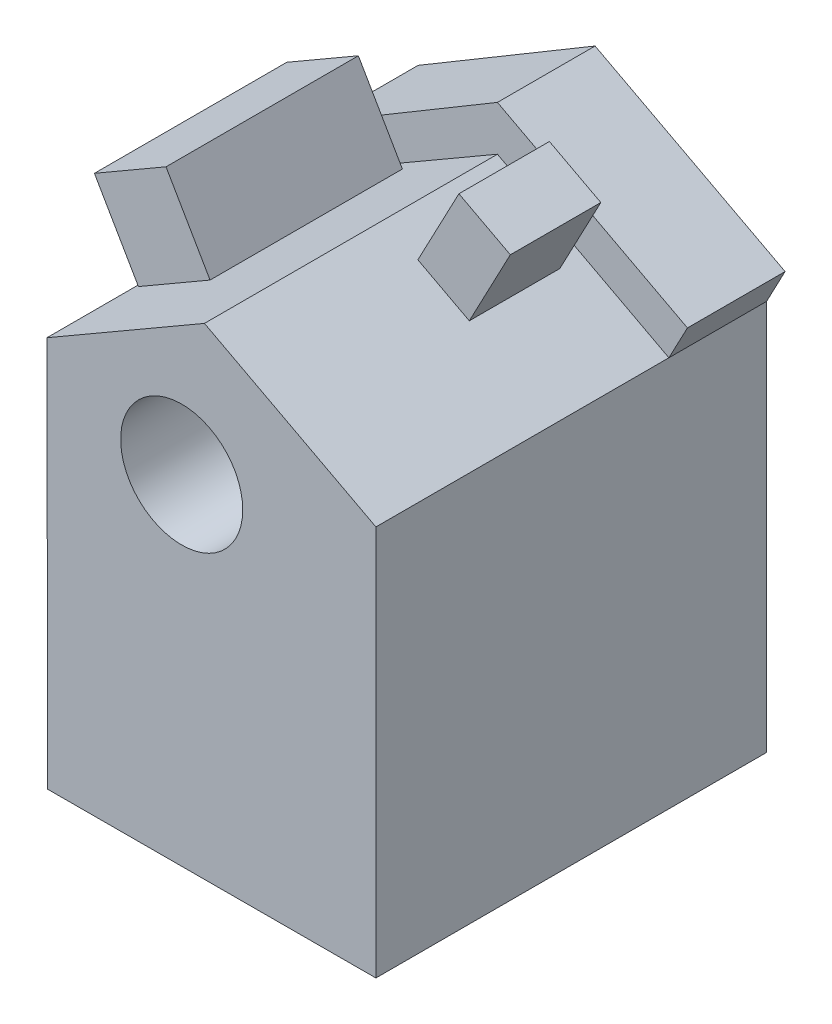
from build123d import *

# Parameters (mm, degrees)
BOSS_EXTRUDE1_DEPTH = 40
SKETCH5_R           = 6.25
CUT_EXTRUDE6_DEPTH  = 10
BOSS_EXTRUDE2_DEPTH = 10
SKETCH8_W           = 5.952717485
SKETCH8_H           = 9.266101102
BOSS_EXTRUDE3_DEPTH = 9
SKETCH9_W           = 8.470991549
SKETCH9_H           = 19.695284028
BOSS_EXTRUDE4_DEPTH = 9


with BuildPart() as part:
    # Sketch4 → Boss-Extrude1 (new body)
    with BuildSketch(Plane.XY):
        Polygon((0, 0), (33.61, 0.067089629), (33.61, 40.067089629), (16.051412556, 49.337388756), (-0.079844843, 40), align=None)
    extrude(amount=BOSS_EXTRUDE1_DEPTH)

    # Sketch5 → Cut-Extrude6 (cut)
    with BuildSketch(Plane.XY.offset(40)):
        with Locations((13.722936718, 34.769875923)):
            Circle(SKETCH5_R)
    extrude(amount=-CUT_EXTRUDE6_DEPTH, mode=Mode.SUBTRACT)

    # Sketch7 → Boss-Extrude2 (add)
    with BuildSketch(Plane.XY):
        Polygon((16.051412556, 49.337388756), (33.61, 40.067089629), (35.508258197, 43.66252189), (16.051412556, 53.935032691), (-2.071528815, 43.157197813), (-0.100967763, 39.843697207), (-0.079558259, 39.856429583), (-0.079844843, 40), align=None)
    extrude(amount=BOSS_EXTRUDE2_DEPTH)

    # Sketch8 → Boss-Extrude3 (add)
    with BuildSketch(Plane(origin=(23.869185445, 45.209887417, 0), x_dir=(0.884316826, -0.466887301, 0), z_dir=(0.466887301, 0.884316826, 0))):
        with Locations((-1.949299392, -16.97326063)):
            Rectangle(SKETCH8_W, SKETCH8_H)
    extrude(amount=BOSS_EXTRUDE3_DEPTH)

    # Sketch9 → Boss-Extrude4 (add)
    with BuildSketch(Plane(origin=(-17.362808636, 29.995959533, 0), x_dir=(0.865467233, 0.500965536, 0), z_dir=(-0.500965536, 0.865467233, 0))):
        with Locations((24.621607571, -21.138745825)):
            Rectangle(SKETCH9_W, SKETCH9_H)
    extrude(amount=BOSS_EXTRUDE4_DEPTH)


solid = part.part
